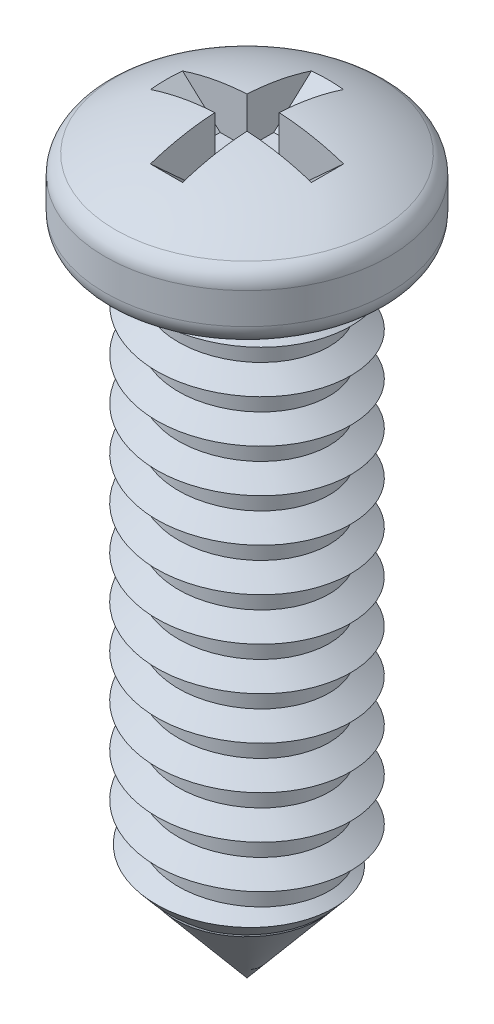
from build123d import *

# Parameters (mm, degrees)
CUT_EXTRUDE_1_DEPTH      = 0.3
PATTERN_CIRCULAR_1_COUNT = 2
PATTERN_CIRCULAR_1_ANGLE = 90


with BuildPart() as part:
    # Sketch 1 → Revolve 3 (revolve)
    with BuildSketch(Plane(origin=(0, 0, 0), x_dir=(0, 0, -1), z_dir=(1, 0, 0)), mode=Mode.PRIVATE) as revolve_3_sk:
        with BuildLine():
            ThreePointArc((2.25, -2), (2.532842712, -1.882842712), (2.65, -1.6))
            Line((2.65, -1.6), (2.65, -1.017085509))
            ThreePointArc((2.65, -1.017085509), (2.599109804, -0.821836066), (2.459388275, -0.676268035))
            ThreePointArc((2.459388275, -0.676268035), (1.277789065, -0.163226887), (0, 0))
            Line((0, 0), (0, -14))
            Line((0, -14), (1.35, -14))
            Line((1.35, -14), (1.35, -2))
            Line((1.35, -2), (2.25, -2))
        make_face()
    revolve(revolve_3_sk.sketch.rotate(Axis((0, 0, 0), (0, -1, 0)), 180), axis=Axis((0, 0, 0), (0, -1, 0)))

    # Sketch 5 → Cut-Extrude 1 (cut, symmetric)
    with BuildSketch(Plane(origin=(0, 0, 0), x_dir=(0, 0, -1), z_dir=(1, 0, 0))):
        Polygon((-2.3, 0.488536713), (-0.8, -0.8838523), (0.8, -0.8838523), (2.3, 0.488536713), align=None)
    cut_extrude_1 = extrude(amount=CUT_EXTRUDE_1_DEPTH, both=True, mode=Mode.SUBTRACT)

    # Pattern Circular 1: Cut-Extrude 1 ×2 about axis
    pattern_circular_1_axis = Axis((0, 0, 0), (0, -1, 0))
    for i in range(1, PATTERN_CIRCULAR_1_COUNT):
        add(cut_extrude_1.rotate(pattern_circular_1_axis, i * PATTERN_CIRCULAR_1_ANGLE / (PATTERN_CIRCULAR_1_COUNT - 1)), mode=Mode.SUBTRACT)

    # Sweep 1: sweep along a curve in space
    with BuildLine() as sweep_1_path:
        add(Edge.make_bspline(
            [(-1.025304833, -1.5, 1.025304833), (-0.433344812, -1.566666667, 1.617264854), (0.375287615, -1.633333333, 1.400592448), (1.183920042, -1.7, 1.183920042), (1.400592448, -1.766666667, 0.375287615), (1.617264854, -1.833333333, -0.433344812), (1.025304833, -1.9, -1.025304833), (0.433344812, -1.966666667, -1.617264854), (-0.375287615, -2.033333333, -1.400592448), (-1.183920042, -2.1, -1.183920042), (-1.400592448, -2.166666667, -0.375287615), (-1.617264854, -2.233333333, 0.433344812), (-1.025304833, -2.3, 1.025304833), (-0.433344812, -2.366666667, 1.617264854), (0.375287615, -2.433333333, 1.400592448), (1.183920042, -2.5, 1.183920042), (1.400592448, -2.566666667, 0.375287615), (1.617264854, -2.633333333, -0.433344812), (1.025304833, -2.7, -1.025304833), (0.433344812, -2.766666667, -1.617264854), (-0.375287615, -2.833333333, -1.400592448), (-1.183920042, -2.9, -1.183920042), (-1.400592448, -2.966666667, -0.375287615), (-1.617264854, -3.033333333, 0.433344812), (-1.025304833, -3.1, 1.025304833), (-0.433344812, -3.166666667, 1.617264854), (0.375287615, -3.233333333, 1.400592448), (1.183920042, -3.3, 1.183920042), (1.400592448, -3.366666667, 0.375287615), (1.617264854, -3.433333333, -0.433344812), (1.025304833, -3.5, -1.025304833), (0.433344812, -3.566666667, -1.617264854), (-0.375287615, -3.633333333, -1.400592448), (-1.183920042, -3.7, -1.183920042), (-1.400592448, -3.766666667, -0.375287615), (-1.617264854, -3.833333333, 0.433344812), (-1.025304833, -3.9, 1.025304833), (-0.433344812, -3.966666667, 1.617264854), (0.375287615, -4.033333333, 1.400592448), (1.183920042, -4.1, 1.183920042), (1.400592448, -4.166666667, 0.375287615), (1.617264854, -4.233333333, -0.433344812), (1.025304833, -4.3, -1.025304833), (0.433344812, -4.366666667, -1.617264854), (-0.375287615, -4.433333333, -1.400592448), (-1.183920042, -4.5, -1.183920042), (-1.400592448, -4.566666667, -0.375287615), (-1.617264854, -4.633333333, 0.433344812), (-1.025304833, -4.7, 1.025304833), (-0.433344812, -4.766666667, 1.617264854), (0.375287615, -4.833333333, 1.400592448), (1.183920042, -4.9, 1.183920042), (1.400592448, -4.966666667, 0.375287615), (1.617264854, -5.033333333, -0.433344812), (1.025304833, -5.1, -1.025304833), (0.433344812, -5.166666667, -1.617264854), (-0.375287615, -5.233333333, -1.400592448), (-1.183920042, -5.3, -1.183920042), (-1.400592448, -5.366666667, -0.375287615), (-1.617264854, -5.433333333, 0.433344812), (-1.025304833, -5.5, 1.025304833), (-0.433344812, -5.566666667, 1.617264854), (0.375287615, -5.633333333, 1.400592448), (1.183920042, -5.7, 1.183920042), (1.400592448, -5.766666667, 0.375287615), (1.617264854, -5.833333333, -0.433344812), (1.025304833, -5.9, -1.025304833), (0.433344812, -5.966666667, -1.617264854), (-0.375287615, -6.033333333, -1.400592448), (-1.183920042, -6.1, -1.183920042), (-1.400592448, -6.166666667, -0.375287615), (-1.617264854, -6.233333333, 0.433344812), (-1.025304833, -6.3, 1.025304833), (-0.433344812, -6.366666667, 1.617264854), (0.375287615, -6.433333333, 1.400592448), (1.183920042, -6.5, 1.183920042), (1.400592448, -6.566666667, 0.375287615), (1.617264854, -6.633333333, -0.433344812), (1.025304833, -6.7, -1.025304833), (0.433344812, -6.766666667, -1.617264854), (-0.375287615, -6.833333333, -1.400592448), (-1.183920042, -6.9, -1.183920042), (-1.400592448, -6.966666667, -0.375287615), (-1.617264854, -7.033333333, 0.433344812), (-1.025304833, -7.1, 1.025304833), (-0.433344812, -7.166666667, 1.617264854), (0.375287615, -7.233333333, 1.400592448), (1.183920042, -7.3, 1.183920042), (1.400592448, -7.366666667, 0.375287615), (1.617264854, -7.433333333, -0.433344812), (1.025304833, -7.5, -1.025304833), (0.433344812, -7.566666667, -1.617264854), (-0.375287615, -7.633333333, -1.400592448), (-1.183920042, -7.7, -1.183920042), (-1.400592448, -7.766666667, -0.375287615), (-1.617264854, -7.833333333, 0.433344812), (-1.025304833, -7.9, 1.025304833), (-0.433344812, -7.966666667, 1.617264854), (0.375287615, -8.033333333, 1.400592448), (1.183920042, -8.1, 1.183920042), (1.400592448, -8.166666667, 0.375287615), (1.617264854, -8.233333333, -0.433344812), (1.025304833, -8.3, -1.025304833), (0.433344812, -8.366666667, -1.617264854), (-0.375287615, -8.433333333, -1.400592448), (-1.183920042, -8.5, -1.183920042), (-1.400592448, -8.566666667, -0.375287615), (-1.617264854, -8.633333333, 0.433344812), (-1.025304833, -8.7, 1.025304833), (-0.433344812, -8.766666667, 1.617264854), (0.375287615, -8.833333333, 1.400592448), (1.183920042, -8.9, 1.183920042), (1.400592448, -8.966666667, 0.375287615), (1.617264854, -9.033333333, -0.433344812), (1.025304833, -9.1, -1.025304833), (0.433344812, -9.166666667, -1.617264854), (-0.375287615, -9.233333333, -1.400592448), (-1.183920042, -9.3, -1.183920042), (-1.400592448, -9.366666667, -0.375287615), (-1.617264854, -9.433333333, 0.433344812), (-1.025304833, -9.5, 1.025304833), (-0.433344812, -9.566666667, 1.617264854), (0.375287615, -9.633333333, 1.400592448), (1.183920042, -9.7, 1.183920042), (1.400592448, -9.766666667, 0.375287615), (1.617264854, -9.833333333, -0.433344812), (1.025304833, -9.9, -1.025304833), (0.433344812, -9.966666667, -1.617264854), (-0.375287615, -10.033333333, -1.400592448), (-1.183920042, -10.1, -1.183920042), (-1.400592448, -10.166666667, -0.375287615), (-1.617264854, -10.233333333, 0.433344812), (-1.025304833, -10.3, 1.025304833), (-0.433344812, -10.366666667, 1.617264854), (0.375287615, -10.433333333, 1.400592448), (1.183920042, -10.5, 1.183920042), (1.400592448, -10.566666667, 0.375287615), (1.617264854, -10.633333333, -0.433344812), (1.025304833, -10.7, -1.025304833), (0.433344812, -10.766666667, -1.617264854), (-0.375287615, -10.833333333, -1.400592448), (-1.183920042, -10.9, -1.183920042), (-1.400592448, -10.966666667, -0.375287615), (-1.617264854, -11.033333333, 0.433344812), (-1.025304833, -11.1, 1.025304833), (-0.433344812, -11.166666667, 1.617264854), (0.375287615, -11.233333333, 1.400592448), (1.183920042, -11.3, 1.183920042), (1.400592448, -11.366666667, 0.375287615), (1.617264854, -11.433333333, -0.433344812), (1.025304833, -11.5, -1.025304833), (0.433344812, -11.566666667, -1.617264854), (-0.375287615, -11.633333333, -1.400592448), (-1.183920042, -11.7, -1.183920042), (-1.400592448, -11.766666667, -0.375287615), (-1.617264854, -11.833333333, 0.433344812), (-1.025304833, -11.9, 1.025304833), (-0.433344812, -11.966666667, 1.617264854), (0.375287615, -12.033333333, 1.400592448), (1.183920042, -12.1, 1.183920042), (1.400592448, -12.166666667, 0.375287615), (1.617264854, -12.233333333, -0.433344812), (1.025304833, -12.3, -1.025304833), (0.433344812, -12.366666667, -1.617264854), (-0.375287615, -12.433333333, -1.400592448), (-1.183920042, -12.5, -1.183920042), (-1.400592448, -12.566666667, -0.375287615), (-1.617264854, -12.633333333, 0.433344812), (-1.025304833, -12.7, 1.025304833), (-0.433344812, -12.766666667, 1.617264854), (0.375287615, -12.833333333, 1.400592448), (1.183920042, -12.9, 1.183920042), (1.400592448, -12.966666667, 0.375287615), (1.617264854, -13.033333333, -0.433344812), (1.025304833, -13.1, -1.025304833), (0.433344812, -13.166666667, -1.617264854), (-0.375287615, -13.233333333, -1.400592448), (-1.183920042, -13.3, -1.183920042), (-1.400592448, -13.366666667, -0.375287615), (-1.617264854, -13.433333333, 0.433344812), (-1.025304833, -13.5, 1.025304833)],
            knots=[0, 0, 0, 0.010416667, 0.010416667, 0.020833333, 0.020833333, 0.03125, 0.03125, 0.041666667, 0.041666667, 0.052083333, 0.052083333, 0.0625, 0.0625, 0.072916667, 0.072916667, 0.083333333, 0.083333333, 0.09375, 0.09375, 0.104166667, 0.104166667, 0.114583333, 0.114583333, 0.125, 0.125, 0.135416667, 0.135416667, 0.145833333, 0.145833333, 0.15625, 0.15625, 0.166666667, 0.166666667, 0.177083333, 0.177083333, 0.1875, 0.1875, 0.197916667, 0.197916667, 0.208333333, 0.208333333, 0.21875, 0.21875, 0.229166667, 0.229166667, 0.239583333, 0.239583333, 0.25, 0.25, 0.260416667, 0.260416667, 0.270833333, 0.270833333, 0.28125, 0.28125, 0.291666667, 0.291666667, 0.302083333, 0.302083333, 0.3125, 0.3125, 0.322916667, 0.322916667, 0.333333333, 0.333333333, 0.34375, 0.34375, 0.354166667, 0.354166667, 0.364583333, 0.364583333, 0.375, 0.375, 0.385416667, 0.385416667, 0.395833333, 0.395833333, 0.40625, 0.40625, 0.416666667, 0.416666667, 0.427083333, 0.427083333, 0.4375, 0.4375, 0.447916667, 0.447916667, 0.458333333, 0.458333333, 0.46875, 0.46875, 0.479166667, 0.479166667, 0.489583333, 0.489583333, 0.5, 0.5, 0.510416667, 0.510416667, 0.520833333, 0.520833333, 0.53125, 0.53125, 0.541666667, 0.541666667, 0.552083333, 0.552083333, 0.5625, 0.5625, 0.572916667, 0.572916667, 0.583333333, 0.583333333, 0.59375, 0.59375, 0.604166667, 0.604166667, 0.614583333, 0.614583333, 0.625, 0.625, 0.635416667, 0.635416667, 0.645833333, 0.645833333, 0.65625, 0.65625, 0.666666667, 0.666666667, 0.677083333, 0.677083333, 0.6875, 0.6875, 0.697916667, 0.697916667, 0.708333333, 0.708333333, 0.71875, 0.71875, 0.729166667, 0.729166667, 0.739583333, 0.739583333, 0.75, 0.75, 0.760416667, 0.760416667, 0.770833333, 0.770833333, 0.78125, 0.78125, 0.791666667, 0.791666667, 0.802083333, 0.802083333, 0.8125, 0.8125, 0.822916667, 0.822916667, 0.833333333, 0.833333333, 0.84375, 0.84375, 0.854166667, 0.854166667, 0.864583333, 0.864583333, 0.875, 0.875, 0.885416667, 0.885416667, 0.895833333, 0.895833333, 0.90625, 0.90625, 0.916666667, 0.916666667, 0.927083333, 0.927083333, 0.9375, 0.9375, 0.9375], degree=2, weights=[1, 0.866025404, 1, 0.866025404, 1, 0.866025404, 1, 0.866025404, 1, 0.866025404, 1, 0.866025404, 1, 0.866025404, 1, 0.866025404, 1, 0.866025404, 1, 0.866025404, 1, 0.866025404, 1, 0.866025404, 1, 0.866025404, 1, 0.866025404, 1, 0.866025404, 1, 0.866025404, 1, 0.866025404, 1, 0.866025404, 1, 0.866025404, 1, 0.866025404, 1, 0.866025404, 1, 0.866025404, 1, 0.866025404, 1, 0.866025404, 1, 0.866025404, 1, 0.866025404, 1, 0.866025404, 1, 0.866025404, 1, 0.866025404, 1, 0.866025404, 1, 0.866025404, 1, 0.866025404, 1, 0.866025404, 1, 0.866025404, 1, 0.866025404, 1, 0.866025404, 1, 0.866025404, 1, 0.866025404, 1, 0.866025404, 1, 0.866025404, 1, 0.866025404, 1, 0.866025404, 1, 0.866025404, 1, 0.866025404, 1, 0.866025404, 1, 0.866025404, 1, 0.866025404, 1, 0.866025404, 1, 0.866025404, 1, 0.866025404, 1, 0.866025404, 1, 0.866025404, 1, 0.866025404, 1, 0.866025404, 1, 0.866025404, 1, 0.866025404, 1, 0.866025404, 1, 0.866025404, 1, 0.866025404, 1, 0.866025404, 1, 0.866025404, 1, 0.866025404, 1, 0.866025404, 1, 0.866025404, 1, 0.866025404, 1, 0.866025404, 1, 0.866025404, 1, 0.866025404, 1, 0.866025404, 1, 0.866025404, 1, 0.866025404, 1, 0.866025404, 1, 0.866025404, 1, 0.866025404, 1, 0.866025404, 1, 0.866025404, 1, 0.866025404, 1, 0.866025404, 1, 0.866025404, 1, 0.866025404, 1, 0.866025404, 1, 0.866025404, 1, 0.866025404, 1, 0.866025404, 1, 0.866025404, 1, 0.866025404, 1, 0.866025404, 1, 0.866025404, 1, 0.866025404, 1, 0.866025404, 1]))
    with BuildLine() as sweep_1_axis:
        Line((0, -1.5, 0), (0, -13.5, 0))
    # Sketch 7 → Sweep 1 (sweep)
    with BuildSketch(Plane(origin=(-1.025304833, -1.5, 1.025304833), x_dir=(0.7090605095787437, 0.051400604926834306, -0.7032717622435071), z_dir=(0.7048752749316127, -0.07938320716719406, 0.7048752749316249))):
        Polygon((0.052099443, 0.250911941), (0.023164844, -0.248250146), (-0.363039312, 0.001330898), align=None)
    sweep(path=sweep_1_path.line, binormal=sweep_1_axis.edges()[0])

    # Sketch 8 → Cut-Revolve 1 (revolve, cut)
    with BuildSketch(Plane(origin=(0, 0, 0), x_dir=(0, 0, -1), z_dir=(1, 0, 0)), mode=Mode.PRIVATE) as cut_revolve_1_sk:
        Polygon((2.5, -11), (0, -14), (0, -35.220635176), (2.5, -35.220635176), align=None)
    revolve(cut_revolve_1_sk.sketch.rotate(Axis((0, 0, 0), (0, -1, 0)), 180), axis=Axis((0, 0, 0), (0, -1, 0)), mode=Mode.SUBTRACT)


solid = part.part
